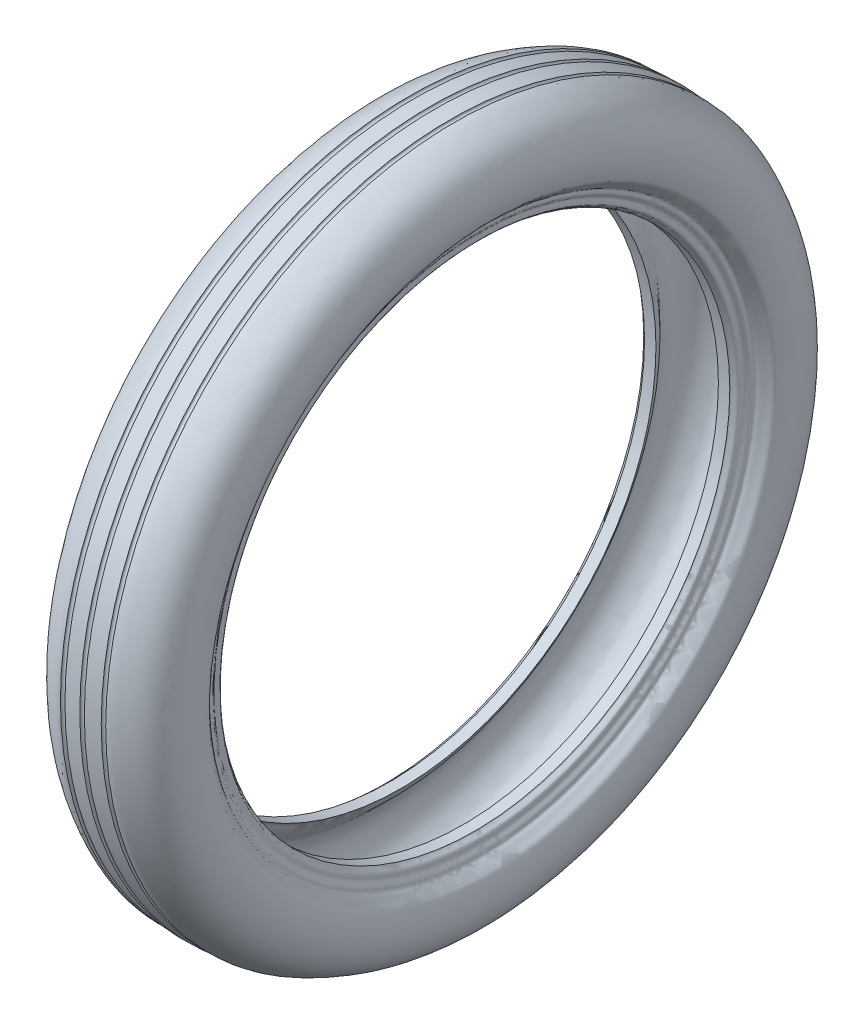
from build123d import *


with BuildPart() as part:
    # Sketch1 → Revolve2 (revolve)
    with BuildSketch(Plane.XY):
        with BuildLine():
            Line((-24.817263014, 203), (-33.905274822, 203))
            add(Edge.make_bspline(
                [(-33.905274822, 203), (-34.451447712, 204.223315441), (-38.405176851, 205.210772848), (-37.589519666, 208.70245477), (-37.317673012, 211.637363166), (-40.367929344, 213.465220786), (-39.066067659, 217.086806756), (-42.529958862, 218.987124675), (-44.481203146, 222.024976144), (-48.1613249, 224.664233071), (-49.33731008, 231.297261903), (-50.56597037, 239.217588361), (-49.541908918, 249.30983287), (-46.425779413, 258.78583291), (-40.684911603, 266.454028141), (-33.868828279, 271.544671241), (-26.584866167, 275.239525499), (-21.384950053, 277.770418692), (-18.001254158, 277.496758701)],
                knots=[0, 0, 0, 0, 0.050284902, 0.080963925, 0.097205761, 0.139297033, 0.164562111, 0.19518801, 0.242420179, 0.280702553, 0.328072426, 0.440671497, 0.533149824, 0.638161135, 0.74644004, 0.823682365, 0.899584942, 1, 1, 1, 1], degree=3))
            ThreePointArc((-18.001254158, 277.496758701), (-16.21574569, 275.711250233), (-14.430237221, 277.496758701))
            Line((-14.430237221, 277.496758701), (-1.819058655, 278.30325082))
            ThreePointArc((-1.819058655, 278.30325082), (0, 276.484192165), (1.819058655, 278.30325082))
            Line((1.819058655, 278.30325082), (14.430237221, 277.496758701))
            ThreePointArc((14.430237221, 277.496758701), (16.21574569, 275.711250233), (18.001254158, 277.496758701))
            add(Edge.make_bspline(
                [(33.905274822, 203), (34.451447712, 204.223315441), (38.405176851, 205.210772848), (37.589519666, 208.70245477), (37.317673012, 211.637363166), (40.367929344, 213.465220786), (39.066067659, 217.086806756), (42.529958862, 218.987124675), (44.481203146, 222.024976144), (48.1613249, 224.664233071), (49.33731008, 231.297261903), (50.56597037, 239.217588361), (49.541908918, 249.30983287), (46.425779413, 258.78583291), (40.684911603, 266.454028141), (33.868828279, 271.544671241), (26.584866167, 275.239525499), (21.384950053, 277.770418692), (18.001254158, 277.496758701)],
                knots=[0, 0, 0, 0, 0.050284902, 0.080963925, 0.097205761, 0.139297033, 0.164562111, 0.19518801, 0.242420179, 0.280702553, 0.328072426, 0.440671497, 0.533149824, 0.638161135, 0.74644004, 0.823682365, 0.899584942, 1, 1, 1, 1], degree=3))
            Line((33.905274822, 203), (24.817263014, 203))
            add(Edge.make_bspline(
                [(24.817263014, 203), (27.228399829, 205.063914319), (28.549642734, 210.327625908), (33.671254535, 215.019378984), (37.777297666, 219.010363555), (42.263357726, 223.06202027), (45.167120419, 229.553937912), (48.02866542, 236.657792056), (47.887967472, 244.882513096), (46.394877316, 254.057111446), (40.348692935, 261.403587544), (33.851481322, 268.810867069), (25.244417526, 271.404992131), (16.742331219, 273.186419121), (10.140554755, 273.463220362), (4.544295124, 274.014061695), (1.753402076, 273.445280921), (0, 273.651830629)],
                knots=[0, 0, 0, 0, 0.082233062, 0.137617147, 0.183009303, 0.237253629, 0.297469874, 0.371716048, 0.44060469, 0.515818014, 0.616103803, 0.690267434, 0.776013818, 0.849380325, 0.924772593, 0.95299048, 1, 1, 1, 1], degree=3))
            add(Edge.make_bspline(
                [(-24.817263014, 203), (-27.228399829, 205.063914319), (-28.549642734, 210.327625908), (-33.671254535, 215.019378984), (-37.777297666, 219.010363555), (-42.263357726, 223.06202027), (-45.167120419, 229.553937912), (-48.02866542, 236.657792056), (-47.887967472, 244.882513096), (-46.394877316, 254.057111446), (-40.348692935, 261.403587544), (-33.851481322, 268.810867069), (-25.244417526, 271.404992131), (-16.742331219, 273.186419121), (-10.140554755, 273.463220362), (-4.544295124, 274.014061695), (-1.753402076, 273.445280921), (0, 273.651830629)],
                knots=[0, 0, 0, 0, 0.082233062, 0.137617147, 0.183009303, 0.237253629, 0.297469874, 0.371716048, 0.44060469, 0.515818014, 0.616103803, 0.690267434, 0.776013818, 0.849380325, 0.924772593, 0.95299048, 1, 1, 1, 1], degree=3))
        make_face()
    revolve(axis=Axis((-102.722911075, 0, 0), (1, 0, 0)))


solid = part.part
